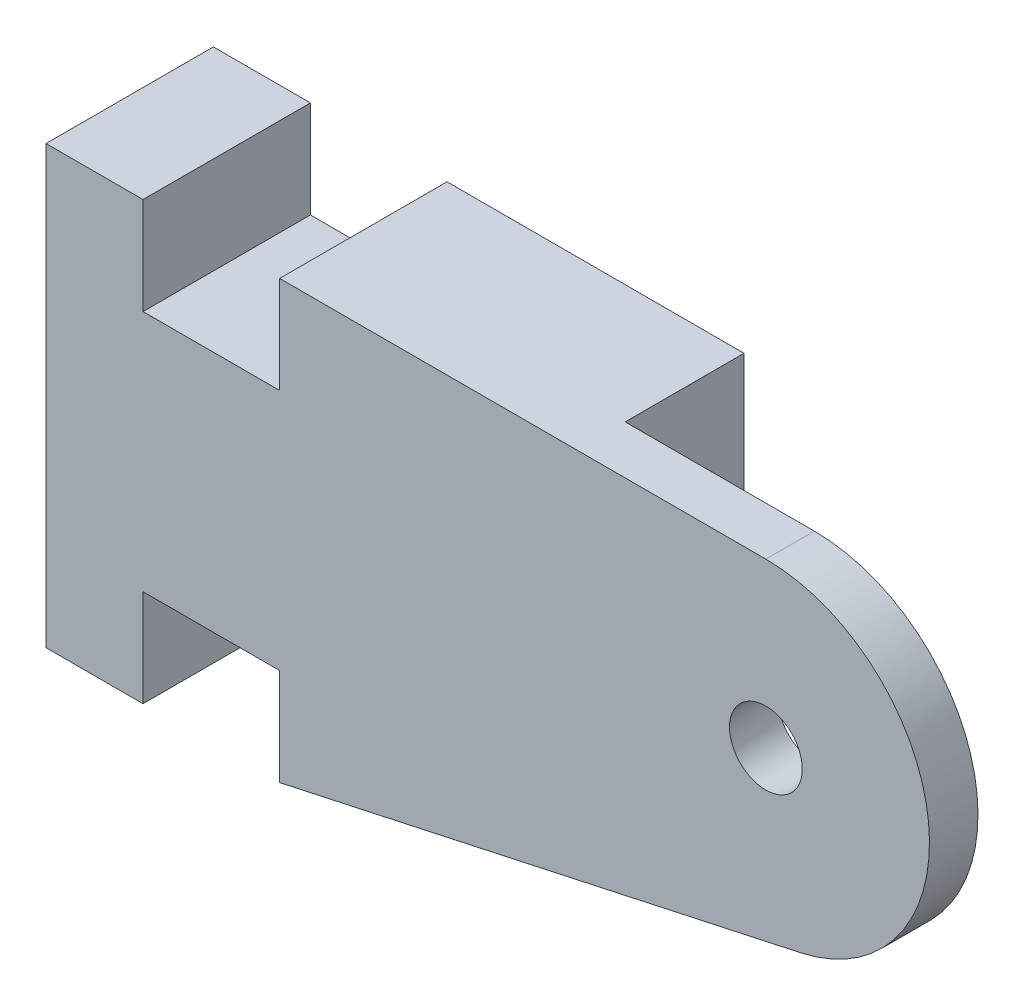
from build123d import *

# Parameters (mm, degrees)
SKETCH1_R           = 1.5
BOSS_EXTRUDE1_DEPTH = 6.9
CUT_EXTRUDE2_DEPTH  = 4.9
SKETCH5_R           = 1
CUT_EXTRUDE3_DEPTH  = 14
SKETCH8_R           = 1
CUT_EXTRUDE5_DEPTH  = 17


with BuildPart() as part:
    # Sketch1 → Boss-Extrude1 (new body)
    with BuildSketch(Plane.XY):
        with BuildLine():
            Line((9.631516349, 18.000341084), (29.676516349, 18.000341084))
            ThreePointArc((29.676516349, 18.000341084), (36.383041872, 11.97511352), (31.10792826, 4.663887347))
            Line((31.10792826, 4.663887347), (9.631516349, 0))
            Line((9.631516349, 0), (9.631516349, 4))
            Line((9.631516349, 4), (4, 4))
            Line((4, 4), (4, 0))
            Line((4, 0), (0, 0))
            Line((0, 0), (0, 18.000341084))
            Line((0, 18.000341084), (4, 18.000341084))
            Line((4, 18.000341084), (4, 14.000341084))
            Line((4, 14.000341084), (9.631516349, 14.000341084))
            Line((9.631516349, 14.000341084), (9.631516349, 18.000341084))
        make_face()
        with Locations((29.676516349, 11.255296941)):
            Circle(SKETCH1_R, mode=Mode.SUBTRACT)
    extrude(amount=BOSS_EXTRUDE1_DEPTH)

    # Sketch4 → Cut-Extrude2 (cut)
    with BuildSketch(Plane.XY):
        with BuildLine():
            Line((21.876472206, 2.659154375), (21.876472206, 18.000341084))
            Line((21.876472206, 18.000341084), (29.676516349, 18.000341084))
            ThreePointArc((29.676516349, 18.000341084), (36.383041872, 11.97511352), (31.10792826, 4.663887347))
            Line((31.10792826, 4.663887347), (31.10792826, 2.659154375))
            Line((31.10792826, 2.659154375), (21.876472206, 2.659154375))
        make_face()
    extrude(amount=CUT_EXTRUDE2_DEPTH, mode=Mode.SUBTRACT)

    # Sketch5 → Cut-Extrude3 (cut)
    with BuildSketch(Plane.ZY):
        with Locations((2.45, 8)):
            Circle(SKETCH5_R)
    extrude(amount=-CUT_EXTRUDE3_DEPTH, mode=Mode.SUBTRACT)

    # Sketch8 → Cut-Extrude5 (cut)
    with BuildSketch(Plane(origin=(19.746237848, -5.290988485, 0), x_dir=(0, 0, -1), z_dir=(0.965925826, -0.258819045, 0))):
        with Locations((-2.45, 11.2)):
            Circle(SKETCH8_R)
    extrude(amount=-CUT_EXTRUDE5_DEPTH, mode=Mode.SUBTRACT)


solid = part.part
